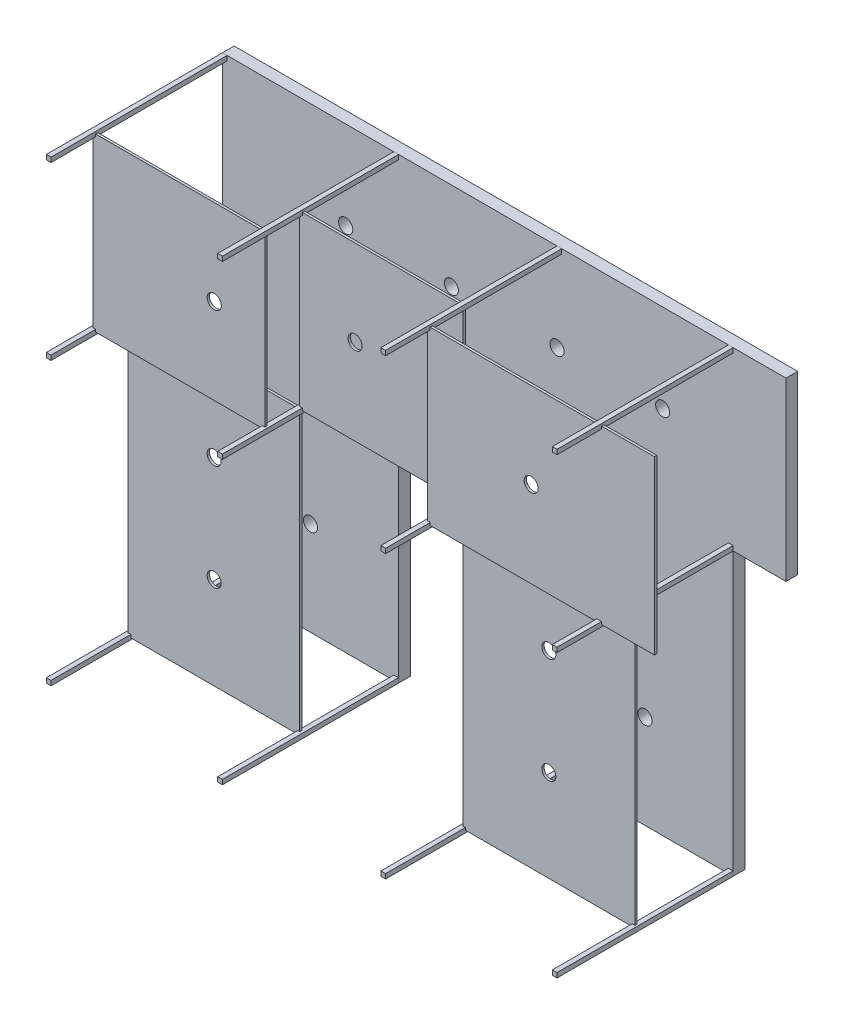
from build123d import *

# Parameters (mm, degrees)
SKETCH1_R              = 60
BOSS_EXTRUDE1_DEPTH    = 100
SKETCH2_W              = 40
SKETCH2_H              = 40
BOSS_EXTRUDE2_DEPTH    = 1500
BOSS_EXTRUDE2_2_DEPTH  = 1500
BOSS_EXTRUDE2_3_DEPTH  = 1500
BOSS_EXTRUDE2_4_DEPTH  = 1500
BOSS_EXTRUDE2_5_DEPTH  = 1500
BOSS_EXTRUDE2_6_DEPTH  = 1500
BOSS_EXTRUDE2_7_DEPTH  = 1500
BOSS_EXTRUDE2_8_DEPTH  = 1500
BOSS_EXTRUDE2_9_DEPTH  = 1500
BOSS_EXTRUDE2_10_DEPTH = 1500
BOSS_EXTRUDE2_11_DEPTH = 1500
BOSS_EXTRUDE2_12_DEPTH = 1500
SKETCH5_W              = 1464.914680954
SKETCH5_H              = 1460.602204205
SKETCH5_W_2            = 1931.254962966
SKETCH5_H_2            = 1462.971886732
BOSS_EXTRUDE5_DEPTH    = 20
SKETCH3_W              = 1460.142152684
SKETCH3_H              = 2406.089345402
SKETCH3_W_2            = 1393.373517389
SKETCH3_H_2            = 1462.042486102
SKETCH3_W_3            = 1462.322698413
SKETCH3_H_3            = 2400.049528254
BOSS_EXTRUDE6_DEPTH    = 20
SKETCH6_R              = 60
SKETCH6_R_2            = 60.379118357
CUT_EXTRUDE2_DEPTH     = 1601


with BuildPart() as part:
    # Sketch1 → Boss-Extrude1 (new body)
    with BuildSketch(Plane.XY):
        Polygon((0, 0), (0, 3900), (4800, 3900), (4800, 2400), (4350, 2400), (4350, 0), (2850, 0), (2850, 2400), (1500, 2400), (1500, 0), align=None)
        with Locations((1050, 3150)):
            Circle(SKETCH1_R, mode=Mode.SUBTRACT)
        with Locations((1950, 3150)):
            Circle(SKETCH1_R, mode=Mode.SUBTRACT)
        with Locations((2850, 3150)):
            Circle(SKETCH1_R, mode=Mode.SUBTRACT)
        with Locations((750, 800)):
            Circle(SKETCH1_R, mode=Mode.SUBTRACT)
        with Locations((3600, 800)):
            Circle(SKETCH1_R, mode=Mode.SUBTRACT)
        with Locations((3600, 1700)):
            Circle(SKETCH1_R, mode=Mode.SUBTRACT)
        with Locations((750, 1700)):
            Circle(SKETCH1_R, mode=Mode.SUBTRACT)
        with Locations((3750, 3150)):
            Circle(SKETCH1_R, mode=Mode.SUBTRACT)
        with Locations((750, 2600)):
            Circle(SKETCH1_R, mode=Mode.SUBTRACT)
        with Locations((3600, 2600)):
            Circle(SKETCH1_R, mode=Mode.SUBTRACT)
    extrude(amount=BOSS_EXTRUDE1_DEPTH)


with BuildPart() as body_2:
    # Sketch2 → Boss-Extrude2 (new body)
    with BuildSketch(Plane.XY.offset(100)):
        with Locations((2870, 2420)):
            Rectangle(SKETCH2_W, SKETCH2_H)
    extrude(amount=BOSS_EXTRUDE2_DEPTH)



with BuildPart() as body_3:
    # Sketch2 → Boss-Extrude2 2 (new body)
    with BuildSketch(Plane.XY.offset(100)):
        with Locations((20, 3880)):
            Rectangle(SKETCH2_W, SKETCH2_H)
    extrude(amount=BOSS_EXTRUDE2_2_DEPTH)



with BuildPart() as body_4:
    # Sketch2 → Boss-Extrude2 3 (new body)
    with BuildSketch(Plane.XY.offset(100)):
        with Locations((20, 20)):
            Rectangle(SKETCH2_W, SKETCH2_H)
    extrude(amount=BOSS_EXTRUDE2_3_DEPTH)


with BuildPart() as body_5:
    # Sketch2 → Boss-Extrude2 4 (new body)
    with BuildSketch(Plane.XY.offset(100)):
        with Locations((1480, 20)):
            Rectangle(SKETCH2_W, SKETCH2_H)
    extrude(amount=BOSS_EXTRUDE2_4_DEPTH)


with BuildPart() as body_6:
    # Sketch2 → Boss-Extrude2 5 (new body)
    with BuildSketch(Plane.XY.offset(100)):
        with Locations((1480, 2420)):
            Rectangle(SKETCH2_W, SKETCH2_H)
    extrude(amount=BOSS_EXTRUDE2_5_DEPTH)


with BuildPart() as body_7:
    # Sketch2 → Boss-Extrude2 6 (new body)
    with BuildSketch(Plane.XY.offset(100)):
        with Locations((1480, 3880)):
            Rectangle(SKETCH2_W, SKETCH2_H)
    extrude(amount=BOSS_EXTRUDE2_6_DEPTH)


with BuildPart() as body_8:
    # Sketch2 → Boss-Extrude2 7 (new body)
    with BuildSketch(Plane.XY.offset(100)):
        with Locations((4330, 20)):
            Rectangle(SKETCH2_W, SKETCH2_H)
    extrude(amount=BOSS_EXTRUDE2_7_DEPTH)


with BuildPart() as body_9:
    # Sketch2 → Boss-Extrude2 8 (new body)
    with BuildSketch(Plane.XY.offset(100)):
        with Locations((2870, 20)):
            Rectangle(SKETCH2_W, SKETCH2_H)
    extrude(amount=BOSS_EXTRUDE2_8_DEPTH)


with BuildPart() as body_10:
    # Sketch2 → Boss-Extrude2 9 (new body)
    with BuildSketch(Plane.XY.offset(100)):
        with Locations((4330, 2420)):
            Rectangle(SKETCH2_W, SKETCH2_H)
    extrude(amount=BOSS_EXTRUDE2_9_DEPTH)


with BuildPart() as body_11:
    # Sketch2 → Boss-Extrude2 10 (new body)
    with BuildSketch(Plane.XY.offset(100)):
        with Locations((4330, 3880)):
            Rectangle(SKETCH2_W, SKETCH2_H)
    extrude(amount=BOSS_EXTRUDE2_10_DEPTH)


with BuildPart() as body_12:
    # Sketch2 → Boss-Extrude2 11 (new body)
    with BuildSketch(Plane.XY.offset(100)):
        with Locations((2870, 3880)):
            Rectangle(SKETCH2_W, SKETCH2_H)
    extrude(amount=BOSS_EXTRUDE2_11_DEPTH)


with BuildPart() as body_13:
    # Sketch2 → Boss-Extrude2 12 (new body)
    with BuildSketch(Plane.XY.offset(100)):
        with Locations((20, 2420)):
            Rectangle(SKETCH2_W, SKETCH2_H)
    extrude(amount=BOSS_EXTRUDE2_12_DEPTH)


with BuildPart() as body_3_1:
    add(body_3.part)

    add(body_7.part)  # Boss-Extrude5 merges body 7

    add(body_11.part)  # Boss-Extrude5 merges body 11

    add(body_12.part)  # Boss-Extrude5 merges body 12
    # Sketch5 → Boss-Extrude5 (add)
    with BuildSketch(Plane.XY.offset(1200)):
        with Locations((748.808177736, 3150.301102103)):
            Rectangle(SKETCH5_W, SKETCH5_H)
        with Locations((3834.372518517, 3149.116260839)):
            Rectangle(SKETCH5_W_2, SKETCH5_H_2)
    extrude(amount=BOSS_EXTRUDE5_DEPTH)


with BuildPart() as body_2_1:
    add(body_2.part)

    add(body_3_1.part)  # Boss-Extrude6 merges body 3

    add(body_4.part)  # Boss-Extrude6 merges body 4

    add(body_5.part)  # Boss-Extrude6 merges body 5

    add(body_6.part)  # Boss-Extrude6 merges body 6

    add(body_8.part)  # Boss-Extrude6 merges body 8

    add(body_9.part)  # Boss-Extrude6 merges body 9

    add(body_10.part)  # Boss-Extrude6 merges body 10

    add(body_13.part)  # Boss-Extrude6 merges body 13
    # Sketch3 → Boss-Extrude6 (add)
    with BuildSketch(Plane.XY.offset(900)):
        with Locations((747.147288346, 1217.004855553)):
            Rectangle(SKETCH3_W, SKETCH3_H)
        with Locations((2173.905123383, 3151.070771305)):
            Rectangle(SKETCH3_W_2, SKETCH3_H_2)
        with Locations((3601.753231284, 1220.024764127)):
            Rectangle(SKETCH3_W_3, SKETCH3_H_3)
    extrude(amount=BOSS_EXTRUDE6_DEPTH)


with BuildPart() as cut_extrude2_tool:
    # Sketch6 → Cut-Extrude2 (new body, through all)
    with BuildSketch(Plane(origin=(0, 0, 0), x_dir=(-1, 0, 0), z_dir=(0, 0, -1))):
        with Locations((-3750, 3150)):
            Circle(SKETCH6_R)
        with Locations((-1050, 3150)):
            Circle(SKETCH6_R_2)
        with Locations((-750, 1700)):
            Circle(SKETCH6_R)
        with Locations((-750, 800)):
            Circle(SKETCH6_R)
        with Locations((-3600, 800)):
            Circle(SKETCH6_R)
        with Locations((-3600, 1700)):
            Circle(SKETCH6_R)
        with Locations((-1950, 3150)):
            Circle(SKETCH6_R)
    extrude(amount=-CUT_EXTRUDE2_DEPTH)


with BuildPart() as part_1:
    add(part.part)

    # Cut-Extrude2: cut by cut_extrude2_tool
    add(cut_extrude2_tool.part, mode=Mode.SUBTRACT)


with BuildPart() as body_2_2:
    add(body_2_1.part)

    # Cut-Extrude2: cut by cut_extrude2_tool
    add(cut_extrude2_tool.part, mode=Mode.SUBTRACT)


solid = Compound([part_1.part, body_2_2.part])
